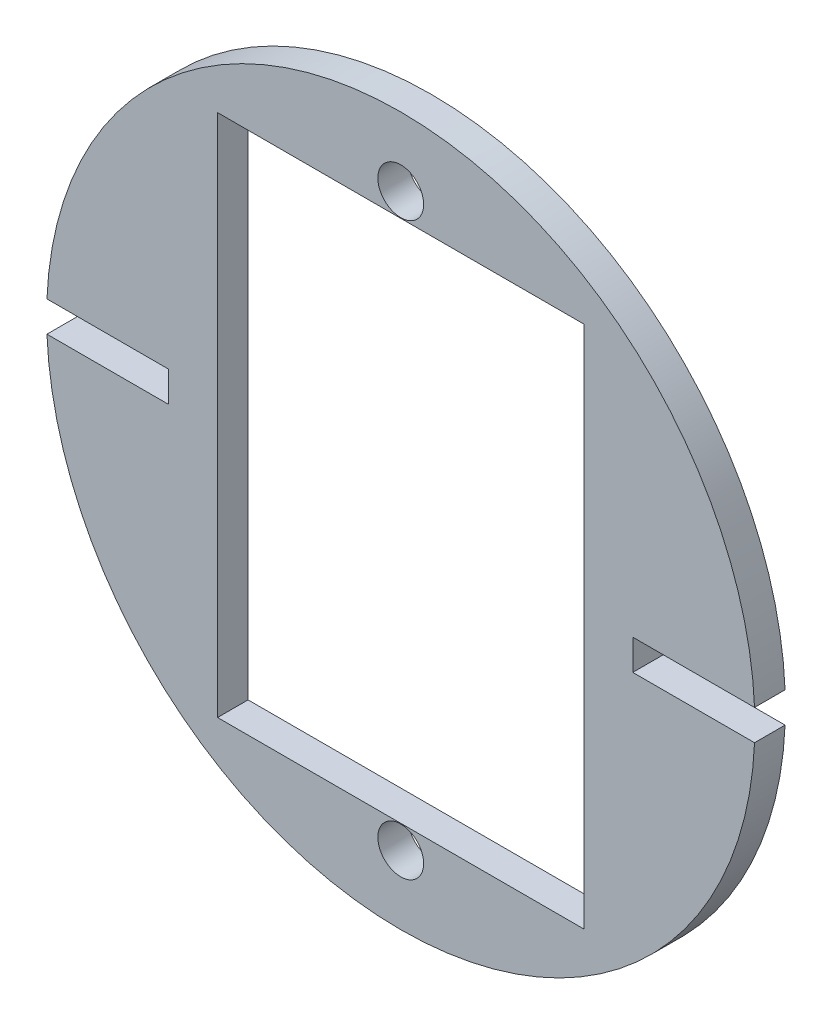
from build123d import *

# Parameters (mm, degrees)
SKETCH1_R           = 73.66
BOSS_EXTRUDE1_DEPTH = 6.35
CUT_EXTRUDE1_DEPTH  = 7.35
SKETCH4_R           = 4.7625
CUT_EXTRUDE2_DEPTH  = 7.35
SKETCH5_W           = 76.2
SKETCH5_H           = 108.966
CUT_EXTRUDE5_DEPTH  = 7.35


with BuildPart() as part:
    # Sketch1 → Boss-Extrude1 (new body)
    with BuildSketch(Plane.XY):
        Circle(SKETCH1_R)
    extrude(amount=BOSS_EXTRUDE1_DEPTH)

    # Sketch2 → Cut-Extrude1 (cut, through all)
    with BuildSketch(Plane(origin=(0, 0, 0), x_dir=(-1, 0, 0), z_dir=(0, 0, -1))):
        Polygon((-48.26, 0), (-48.26, 3.175), (-76.2, 3.175), (-76.2, -3.175), (-48.26, -3.175), align=None)
        Polygon((48.26, -3.175), (48.26, 0), (48.26, 3.175), (76.2, 3.175), (76.2, -3.175), align=None)
    extrude(amount=-CUT_EXTRUDE1_DEPTH, mode=Mode.SUBTRACT)

    # Sketch4 → Cut-Extrude2 (cut, through all)
    with BuildSketch(Plane(origin=(0, 0, 0), x_dir=(-1, 0, 0), z_dir=(0, 0, -1))):
        with Locations((0, -59.3725)):
            Circle(SKETCH4_R)
        with Locations((0, 59.3725)):
            Circle(SKETCH4_R)
    extrude(amount=-CUT_EXTRUDE2_DEPTH, mode=Mode.SUBTRACT)

    # Sketch5 → Cut-Extrude5 (cut, through all)
    with BuildSketch(Plane(origin=(0, 0, 0), x_dir=(-1, 0, 0), z_dir=(0, 0, -1))):
        Rectangle(SKETCH5_W, SKETCH5_H)
    extrude(amount=-CUT_EXTRUDE5_DEPTH, mode=Mode.SUBTRACT)


solid = part.part
